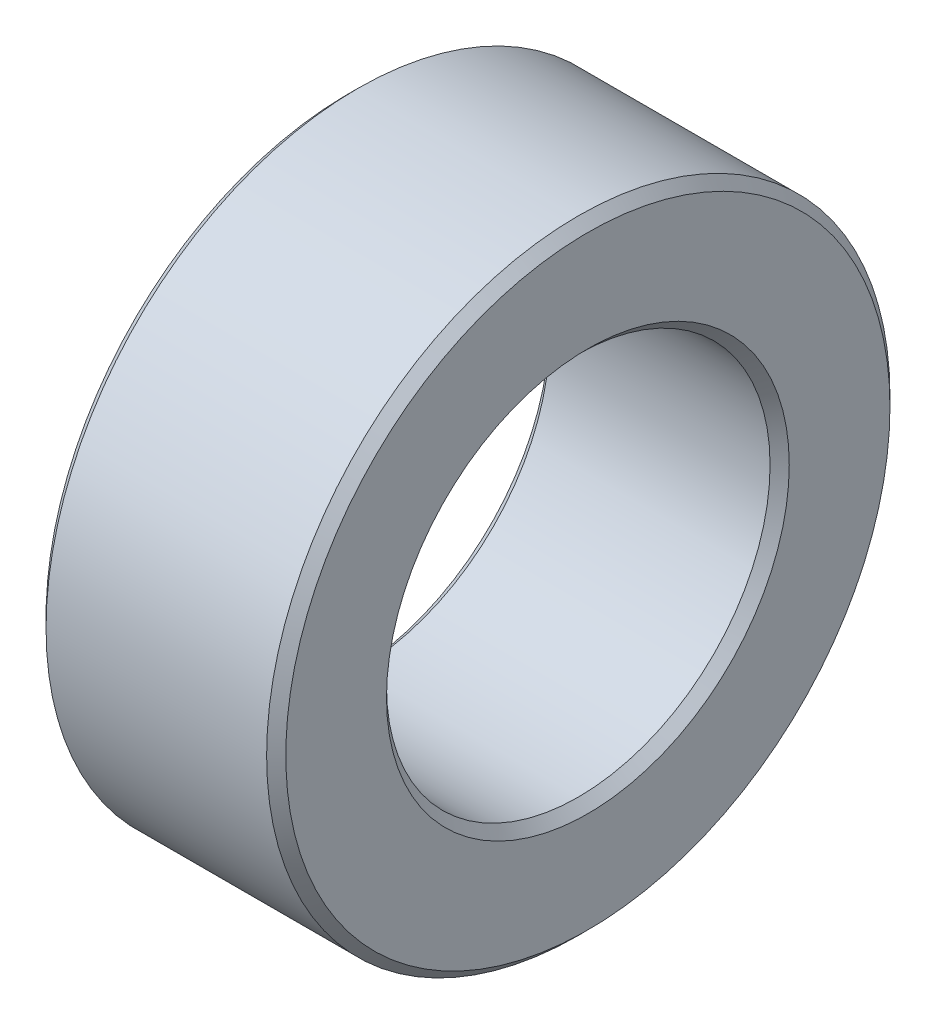
from build123d import *

# Parameters (mm, degrees)
SKETCH1_R           = 6.5
SKETCH1_R_2         = 4
BOSS_EXTRUDE1_DEPTH = 5
CHAMFER1_SIZE       = 0.2


with BuildPart() as part:
    # Sketch1 → Boss-Extrude1 (new body)
    with BuildSketch(Plane(origin=(0, 0, 0), x_dir=(0, 0, -1), z_dir=(1, 0, 0))):
        Circle(SKETCH1_R)
        Circle(SKETCH1_R_2, mode=Mode.SUBTRACT)
    extrude(amount=BOSS_EXTRUDE1_DEPTH)

    # Chamfer1
    chamfer1_edges = [part.edges().sort_by_distance(p)[0] for p in [
        (0, 0, 6.5),
        (5, 0, 6.5),
        (0, 0, 4),
        (5, 0, 4),
    ]]
    chamfer(chamfer1_edges, length=CHAMFER1_SIZE)


solid = part.part
